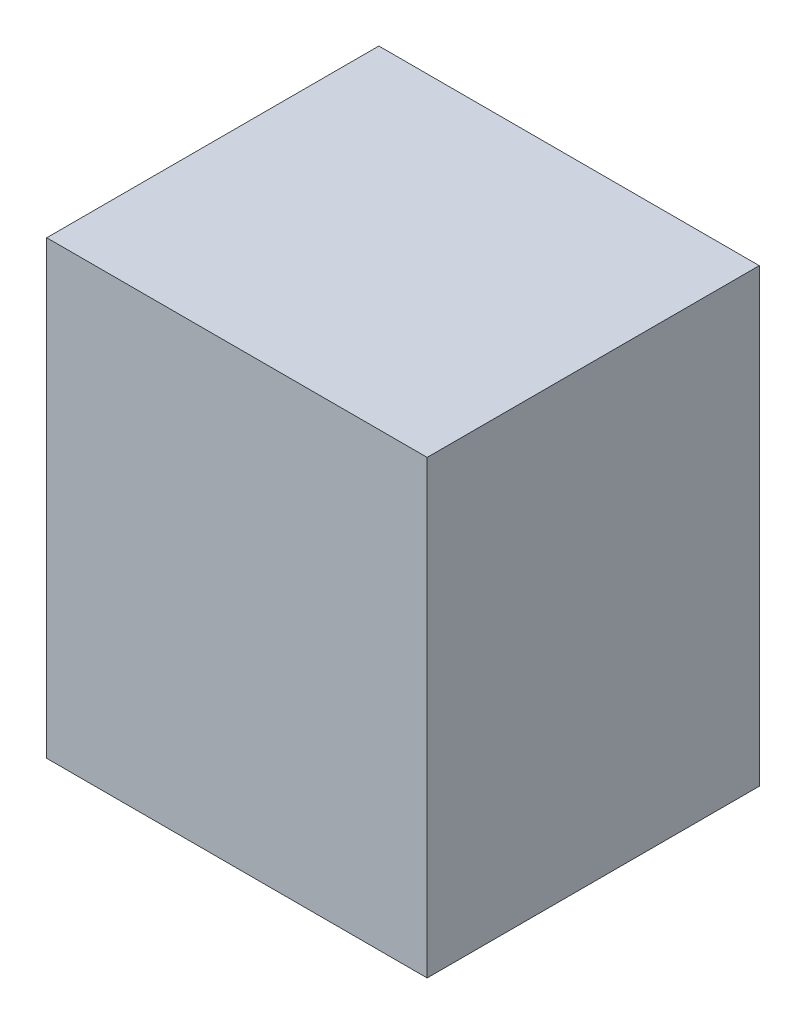
from build123d import *

# Parameters (mm, degrees)
SKETCH1_W           = 480.06
SKETCH1_H           = 419.1
BOSS_EXTRUDE1_DEPTH = 568.96


with BuildPart() as part:
    # Sketch1 → Boss-Extrude1 (new body)
    with BuildSketch(Plane(origin=(0, 0, 0), x_dir=(1, 0, 0), z_dir=(0, 1, 0))):
        with Locations((240.03, -209.55)):
            Rectangle(SKETCH1_W, SKETCH1_H)
    extrude(amount=BOSS_EXTRUDE1_DEPTH)


solid = part.part
